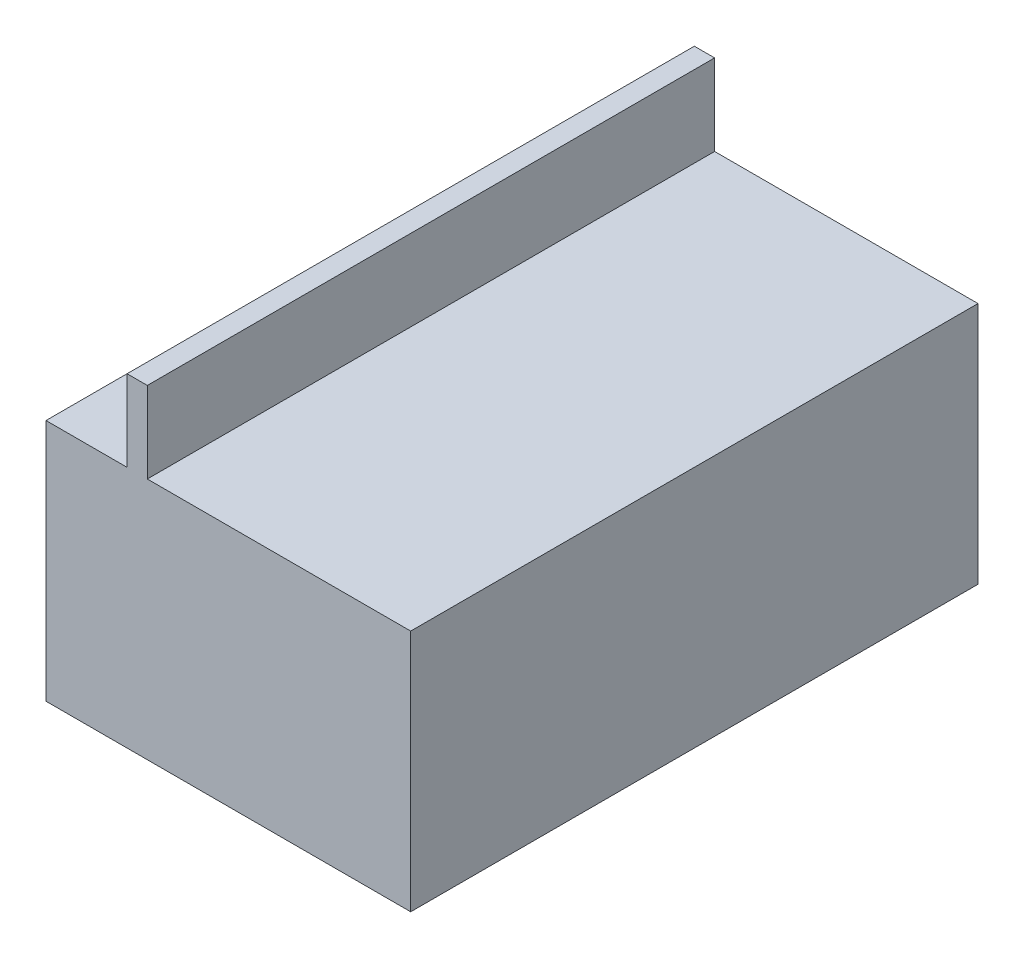
from build123d import *

# Parameters (mm, degrees)
SKETCH1_W           = 90
SKETCH1_H           = 140
BOSS_EXTRUDE1_DEPTH = 60
SKETCH2_W           = 5
SKETCH2_H           = 140
BOSS_EXTRUDE2_DEPTH = 20


with BuildPart() as part:
    # Sketch1 → Boss-Extrude1 (new body)
    with BuildSketch(Plane(origin=(0, 0, 0), x_dir=(1, 0, 0), z_dir=(0, 1, 0))):
        with Locations((45, -70)):
            Rectangle(SKETCH1_W, SKETCH1_H)
    extrude(amount=BOSS_EXTRUDE1_DEPTH)

    # Sketch2 → Boss-Extrude2 (add)
    with BuildSketch(Plane(origin=(0, 60, 0), x_dir=(1, 0, 0), z_dir=(0, 1, 0))):
        with Locations((22.5, -70)):
            Rectangle(SKETCH2_W, SKETCH2_H)
    extrude(amount=BOSS_EXTRUDE2_DEPTH)


solid = part.part
